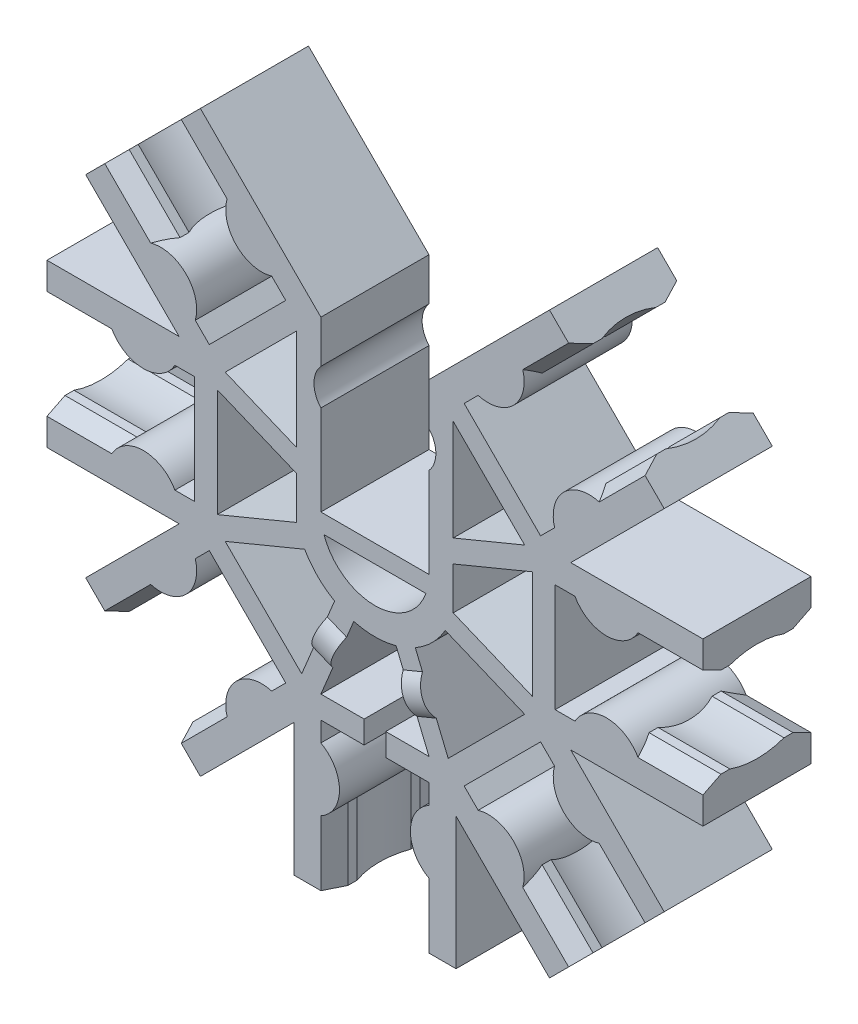
from build123d import *

# Parameters (mm, degrees)
EXTRUDE_1_DEPTH          = 6
EXTRUDE_START            = -3.991967
EXTRUDE_2_DEPTH          = 3.991967
PATTERN_CIRCULAR_1_COUNT = 8
CUT_EXTRUDE_2_DEPTH      = 7.0000001
EXTRUDE_3_DEPTH          = 1.153683
EXTRUDE_4_DEPTH          = 1.153683


with BuildPart() as part:
    # 草图1 → 凸台-拉伸1 (new body)
    with BuildSketch(Plane.XY):
        with BuildLine():
            Line((-4.5, 0), (-4.5, -18.2))
            Line((-4.5, -18.2), (-3, -18.2))
            Line((-3, -18.2), (-3, -14.6))
            ThreePointArc((-3, -14.6), (-1.968245837, -12.85), (-3, -11.1))
            Line((-3, -11.1), (-3, -10))
            Line((-3, -10), (3, -10))
            Line((3, -10), (3, -11.1))
            ThreePointArc((3, -11.1), (1.968245837, -12.85), (3, -14.6))
            Line((3, -14.6), (3, -18.2))
            Line((3, -18.2), (4.5, -18.2))
            Line((4.5, -18.2), (4.5, 0))
            ThreePointArc((4.5, 0), (0, 4.5), (-4.5, 0))
        make_face()
    extrude_1 = extrude(amount=EXTRUDE_1_DEPTH)

    # 草图3 → 凸台-拉伸2 (add)
    with BuildSketch(Plane.XZ.offset(18.2).offset(EXTRUDE_START)):
        with BuildLine():
            Line((-3, 6), (-3, 0))
            Line((-3, 0), (-2.5, 1))
            Line((-2.5, 1), (-2.5, 1.5))
            ThreePointArc((-2.5, 1.5), (-2.757359313, 3), (-2.5, 4.5))
            Line((-2.5, 4.5), (-2.5, 5))
            Line((-2.5, 5), (-3, 6))
        make_face()
        with BuildLine():
            Line((3, 0), (2.5, 1))
            Line((2.5, 1), (2.5, 1.5))
            ThreePointArc((2.5, 1.5), (2.757359313, 3), (2.5, 4.5))
            Line((2.5, 4.5), (2.5, 5))
            Line((2.5, 5), (3, 6))
            Line((3, 6), (3, 0))
        make_face()
    extrude_2 = extrude(amount=EXTRUDE_2_DEPTH)

    # 阵列(圆周)1: 凸台-拉伸1, 凸台-拉伸2 ×8 about axis
    pattern_circular_1_axis = Axis((0, 0, 0), (0, 0, 1))
    for i in range(1, PATTERN_CIRCULAR_1_COUNT):
        add(extrude_1.rotate(pattern_circular_1_axis, i * 360 / PATTERN_CIRCULAR_1_COUNT))
        add(extrude_2.rotate(pattern_circular_1_axis, i * 360 / PATTERN_CIRCULAR_1_COUNT))

    # 草图4 → 切除-拉伸2 (cut, through all)
    with BuildSketch(Plane(origin=(0, 0, 0), x_dir=(-1, 0, 0), z_dir=(0, 0, -1))):
        with BuildLine():
            Line((-3, -8.75), (-0.6, -8.75))
            Line((-0.6, -8.75), (-0.6, -10))
            Line((-0.6, -10), (0.6, -10))
            Line((0.6, -10), (0.6, -8.75))
            Line((0.6, -8.75), (3, -8.75))
            Line((3, -8.75), (1.174936357, -4.343906601))
            ThreePointArc((1.174936357, -4.343906601), (0, -4.5), (-1.174936357, -4.343906601))
            Line((-1.174936357, -4.343906601), (-3, -8.75))
        make_face()
        with BuildLine():
            Line((-8.308504679, -4.065863992), (-3.90241128, -2.240800349))
            ThreePointArc((-3.90241128, -2.240800349), (-3.181980515, -3.181980515), (-2.240800349, -3.90241128))
            Line((-2.240800349, -3.90241128), (-4.065863992, -8.308504679))
            Line((-4.065863992, -8.308504679), (-8.308504679, -4.065863992))
        make_face()
        Polygon((-4.343906601, -1.174936357), (-4.343906601, 1.174936357), (-8.75, 3), (-8.75, -3), align=None)
        Polygon((4.343906601, -1.174936357), (4.343906601, 1.174936357), (8.75, 3), (8.75, -3), align=None)
        Polygon((-4.343906601, 8.03046207), (-8.308504679, 4.065863992), (-4.343906601, 2.423673699), align=None)
        with BuildLine():
            Line((4.065863992, -8.308504679), (2.240800349, -3.90241128))
            ThreePointArc((2.240800349, -3.90241128), (3.181980515, -3.181980515), (3.90241128, -2.240800349))
            Line((3.90241128, -2.240800349), (8.308504679, -4.065863992))
            Line((8.308504679, -4.065863992), (4.065863992, -8.308504679))
        make_face()
        Polygon((8.308504679, 4.065863992), (4.343906601, 8.03046207), (4.343906601, 2.423673699), align=None)
        with BuildLine():
            Line((-4.5, 10.863961031), (-3, 9.363961031))
            Line((-3, 9.363961031), (-3, 7))
            ThreePointArc((-3, 7), (-3.381966011, 6), (-3, 5))
            Line((-3, 5), (-3, 0))
            Line((-3, 0), (0, 0))
            Line((0, 0), (3, 0))
            Line((3, 0), (3, 5))
            ThreePointArc((3, 5), (3.381966011, 6), (3, 7))
            Line((3, 7), (3, 9.363961031))
            Line((3, 9.363961031), (4.5, 10.863961031))
            Line((4.5, 10.863961031), (4.5, 18.2))
            Line((4.5, 18.2), (-4.5, 18.2))
            Line((-4.5, 18.2), (-4.5, 10.863961031))
        make_face()
        with BuildLine():
            Line((-2.828427125, -1), (2.828427125, -1))
            ThreePointArc((2.828427125, -1), (0, -3), (-2.828427125, -1))
        make_face()
    extrude(amount=-CUT_EXTRUDE_2_DEPTH, mode=Mode.SUBTRACT)

    # 草图5 → 凸台-拉伸3 (add)
    with BuildSketch(Plane(origin=(-0.532931996, -0.220747661, 0), x_dir=(0, 0, 1), z_dir=(-0.923879533, -0.382683432, 0))):
        with BuildLine():
            Line((0, -7.5), (0, -5.5))
            ThreePointArc((0, -5.5), (-0.381966011, -6.5), (0, -7.5))
        make_face()
        with BuildLine():
            Line((6, -7.5), (6, -5.5))
            ThreePointArc((6, -5.5), (6.381966011, -6.5), (6, -7.5))
        make_face()
    extrude(amount=-EXTRUDE_3_DEPTH)

    # 草图6 → 凸台-拉伸4 (add)
    with BuildSketch(Plane(origin=(0.532931996, -0.220747661, 0), x_dir=(0, 0, -1), z_dir=(0.923879533, -0.382683432, 0))):
        with BuildLine():
            Line((0, -7.5), (0, -5.5))
            ThreePointArc((0, -5.5), (0.381966011, -6.5), (0, -7.5))
        make_face()
        with BuildLine():
            Line((-6, -7.5), (-6, -5.5))
            ThreePointArc((-6, -5.5), (-6.381966011, -6.5), (-6, -7.5))
        make_face()
    extrude(amount=-EXTRUDE_4_DEPTH)


solid = part.part
